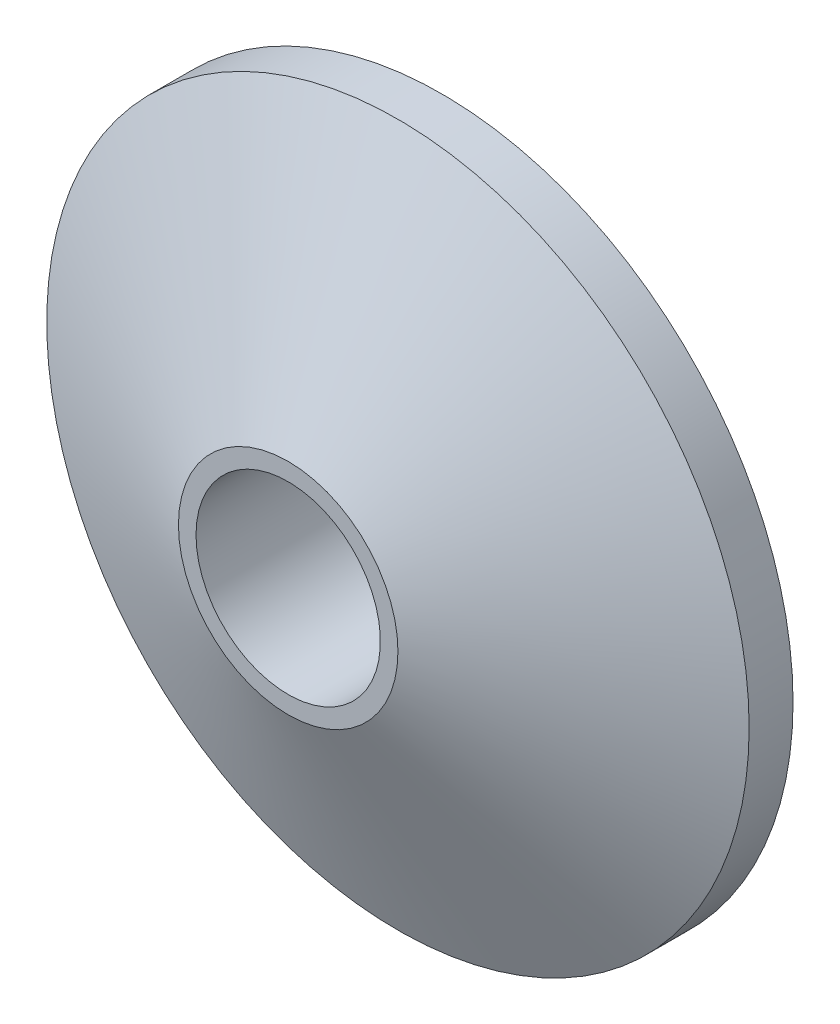
from build123d import *

# Parameters (mm, degrees)
SKETCH1_R                   = 8
BOSS_EXTRUDE1_DEPTH         = 3.5
CHAMFER1_SIZE               = 2.5
CHAMFER1_SIZE2              = 5.5
TAP_DRILL_FOR_M5X0_8_TAP1_D = 4.2


with BuildPart() as part:
    # Sketch1 → Boss-Extrude1 (new body)
    with BuildSketch(Plane.XY):
        Circle(SKETCH1_R)
    extrude(amount=BOSS_EXTRUDE1_DEPTH)

    # Chamfer1
    chamfer1_edges = [part.edges().sort_by_distance(p)[0] for p in [
        (-8, 0, 3.5),
    ]]
    chamfer1_side = [part.faces().sort_by_distance(p)[0] for p in [
        (-8, 0, 1.75),
    ]]
    chamfer(chamfer1_edges, length=CHAMFER1_SIZE, length2=CHAMFER1_SIZE2, reference=chamfer1_side[0])

    # Tap Drill for M5x0.8 Tap1 (through all)
    with Locations(Plane(origin=(0, 0, 0), x_dir=(-1, 0, 0), z_dir=(0, 0, -1))):
        with Locations((0, 0)):
            Hole(TAP_DRILL_FOR_M5X0_8_TAP1_D / 2)


solid = part.part
